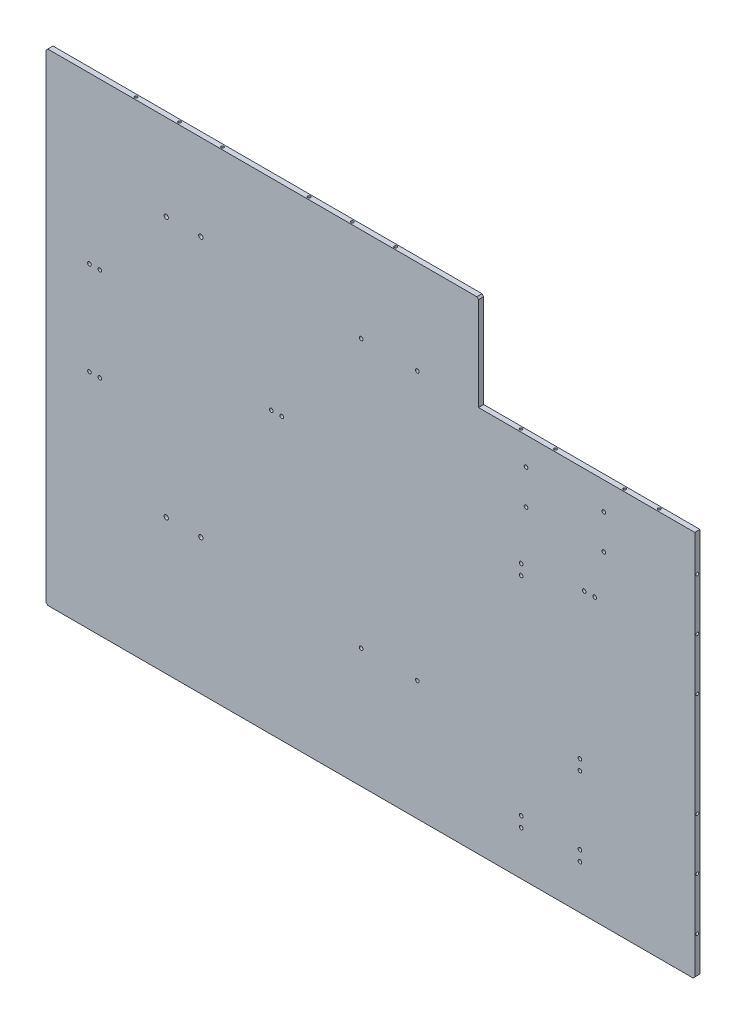
from build123d import *

# Parameters (mm, degrees)
SKETCH_1_W             = 610
SKETCH_1_H             = 420
EXTRUDE_1_DEPTH        = 6
HOLE_WIZARD_M6_1_D     = 5
HOLE_WIZARD_M6_1_DEPTH = 15
HOLE_WIZARD_M6_1_TIP   = 1.502151548
HOLE_WIZARD_M5_1_D     = 4.2
HOLE_WIZARD_M5_1_DEPTH = 12.4
HOLE_WIZARD_M5_1_TIP   = 1.2618073
HOLE_WIZARD_M5_2_D     = 4.2
HOLE_WIZARD_M5_2_DEPTH = 12.4
HOLE_WIZARD_M5_2_TIP   = 1.2618073
HOLE_WIZARD_M6_2_D     = 5
HOLE_WIZARD_M6_2_DEPTH = 15
HOLE_WIZARD_M6_2_TIP   = 1.502151548
HOLE_WIZARD_M5_3_D     = 4.2
HOLE_WIZARD_M5_3_DEPTH = 12.4
HOLE_WIZARD_M5_3_TIP   = 1.2618073
HOLE_WIZARD_M5_4_D     = 4.2
HOLE_WIZARD_M5_4_DEPTH = 12.4
HOLE_WIZARD_M5_4_TIP   = 1.2618073
HOLE_WIZARD_M5_5_D     = 4.2
HOLE_WIZARD_M5_5_DEPTH = 12.4
HOLE_WIZARD_M5_5_TIP   = 1.2618073
HOLE_WIZARD_M5_6_D     = 4.2
HOLE_WIZARD_M5_6_DEPTH = 12.4
HOLE_WIZARD_M5_6_TIP   = 1.2618073
HOLE_WIZARD_M5_7_D     = 4.2
HOLE_WIZARD_M5_7_DEPTH = 12.4
HOLE_WIZARD_M5_7_TIP   = 1.2618073
SKETCH_22_W            = 610
SKETCH_22_H            = 6
EXTRUDE_2_DEPTH        = 47.17
SKETCH_23_W            = 610
SKETCH_23_H            = 6
EXTRUDE_3_DEPTH        = 90
SKETCH_24_W            = 6
SKETCH_24_H            = 557.17
EXTRUDE_4_DEPTH        = 39.94
SKETCH_25_W            = 6
SKETCH_25_H            = 557.17
EXTRUDE_5_DEPTH        = 100.06
SKETCH_26_W            = 250
SKETCH_26_H            = 110
CUT_EXTRUDE_1_DEPTH    = 100.06
CHAMFER_2_SIZE         = 2
CHAMFER_3_SIZE         = 2
CHAMFER_4_SIZE         = 2
CHAMFER_5_SIZE         = 2
HOLE_WIZARD_M4_1_D     = 3.3
HOLE_WIZARD_M4_1_DEPTH = 10.1
HOLE_WIZARD_M4_1_TIP   = 0.991420021
HOLE_WIZARD_M4_2_D     = 3.3
HOLE_WIZARD_M4_2_DEPTH = 10.1
HOLE_WIZARD_M4_2_TIP   = 0.991420021
HOLE_WIZARD_M4_3_D     = 3.3
HOLE_WIZARD_M4_3_DEPTH = 10.1
HOLE_WIZARD_M4_3_TIP   = 0.991420021
HOLE_WIZARD_M4_4_D     = 3.3
HOLE_WIZARD_M4_4_DEPTH = 10.1
HOLE_WIZARD_M4_4_TIP   = 0.991420021
HOLE_WIZARD_M4_5_D     = 3.3
HOLE_WIZARD_M4_5_DEPTH = 10.1
HOLE_WIZARD_M4_5_TIP   = 0.991420021


with BuildPart() as part:
    # 草图1 → 凸台-拉伸1 (new body)
    with BuildSketch(Plane.XY):
        with Locations((305, 210)):
            Rectangle(SKETCH_1_W, SKETCH_1_H)
    extrude(amount=EXTRUDE_1_DEPTH)

    # M6 螺纹孔1
    with Locations(Plane.XY.offset(6)):
        with Locations((99, 410.6), (139, 410.6)):
            Hole(HOLE_WIZARD_M6_1_D / 2, depth=HOLE_WIZARD_M6_1_DEPTH)
            with Locations((0, 0, -(HOLE_WIZARD_M6_1_DEPTH + HOLE_WIZARD_M6_1_TIP / 2))):  # 118° drill point
                Cone(0, HOLE_WIZARD_M6_1_D / 2, HOLE_WIZARD_M6_1_TIP, mode=Mode.SUBTRACT)

    # M5 螺纹孔1
    with Locations(Plane.XY.offset(6)):
        with Locations((10.231581543, 318.9), (22.231581543, 318.9)):
            Hole(HOLE_WIZARD_M5_1_D / 2, depth=HOLE_WIZARD_M5_1_DEPTH)
            with Locations((0, 0, -(HOLE_WIZARD_M5_1_DEPTH + HOLE_WIZARD_M5_1_TIP / 2))):  # 118° drill point
                Cone(0, HOLE_WIZARD_M5_1_D / 2, HOLE_WIZARD_M5_1_TIP, mode=Mode.SUBTRACT)

    # M5 螺纹孔2
    with Locations(Plane.XY.offset(6)):
        with Locations((10.231581543, 210.9), (22.231581543, 210.9)):
            Hole(HOLE_WIZARD_M5_2_D / 2, depth=HOLE_WIZARD_M5_2_DEPTH)
            with Locations((0, 0, -(HOLE_WIZARD_M5_2_DEPTH + HOLE_WIZARD_M5_2_TIP / 2))):  # 118° drill point
                Cone(0, HOLE_WIZARD_M5_2_D / 2, HOLE_WIZARD_M5_2_TIP, mode=Mode.SUBTRACT)

    # M6 螺纹孔2
    with Locations(Plane.XY.offset(6)):
        with Locations((99, 109.6), (139, 109.6)):
            Hole(HOLE_WIZARD_M6_2_D / 2, depth=HOLE_WIZARD_M6_2_DEPTH)
            with Locations((0, 0, -(HOLE_WIZARD_M6_2_DEPTH + HOLE_WIZARD_M6_2_TIP / 2))):  # 118° drill point
                Cone(0, HOLE_WIZARD_M6_2_D / 2, HOLE_WIZARD_M6_2_TIP, mode=Mode.SUBTRACT)

    # M5 螺纹孔3
    with Locations(Plane.XY.offset(6)):
        with Locations((515, 367.9), (515, 327.9), (605, 327.9), (605, 367.9)):
            Hole(HOLE_WIZARD_M5_3_D / 2, depth=HOLE_WIZARD_M5_3_DEPTH)
            with Locations((0, 0, -(HOLE_WIZARD_M5_3_DEPTH + HOLE_WIZARD_M5_3_TIP / 2))):  # 118° drill point
                Cone(0, HOLE_WIZARD_M5_3_D / 2, HOLE_WIZARD_M5_3_TIP, mode=Mode.SUBTRACT)

    # M5 螺纹孔4
    with Locations(Plane.XY.offset(6)):
        with Locations((582.231581543, 277.4), (594.231581543, 277.4), (509.3, 268.5), (509.3, 256.5), (509.3, 16), (509.3, 4), (577.3, 16), (577.3, 4), (577.3, 95), (577.3, 107)):
            Hole(HOLE_WIZARD_M5_4_D / 2, depth=HOLE_WIZARD_M5_4_DEPTH)
            with Locations((0, 0, -(HOLE_WIZARD_M5_4_DEPTH + HOLE_WIZARD_M5_4_TIP / 2))):  # 118° drill point
                Cone(0, HOLE_WIZARD_M5_4_D / 2, HOLE_WIZARD_M5_4_TIP, mode=Mode.SUBTRACT)

    # M5 螺纹孔5
    with Locations(Plane.XY.offset(6)):
        with Locations((220.520192359, 277.4), (232.520192359, 277.4)):
            Hole(HOLE_WIZARD_M5_5_D / 2, depth=HOLE_WIZARD_M5_5_DEPTH)
            with Locations((0, 0, -(HOLE_WIZARD_M5_5_DEPTH + HOLE_WIZARD_M5_5_TIP / 2))):  # 118° drill point
                Cone(0, HOLE_WIZARD_M5_5_D / 2, HOLE_WIZARD_M5_5_TIP, mode=Mode.SUBTRACT)

    # M5 螺纹孔6
    with Locations(Plane.XY.offset(6)):
        with Locations((324.3072517, 91.214749506), (389.3072517, 91.214749506)):
            Hole(HOLE_WIZARD_M5_6_D / 2, depth=HOLE_WIZARD_M5_6_DEPTH)
            with Locations((0, 0, -(HOLE_WIZARD_M5_6_DEPTH + HOLE_WIZARD_M5_6_TIP / 2))):  # 118° drill point
                Cone(0, HOLE_WIZARD_M5_6_D / 2, HOLE_WIZARD_M5_6_TIP, mode=Mode.SUBTRACT)

    # M5 螺纹孔7
    with Locations(Plane.XY.offset(6)):
        with Locations((324.3072517, 401.214749506), (389.3072517, 401.214749506)):
            Hole(HOLE_WIZARD_M5_7_D / 2, depth=HOLE_WIZARD_M5_7_DEPTH)
            with Locations((0, 0, -(HOLE_WIZARD_M5_7_DEPTH + HOLE_WIZARD_M5_7_TIP / 2))):  # 118° drill point
                Cone(0, HOLE_WIZARD_M5_7_D / 2, HOLE_WIZARD_M5_7_TIP, mode=Mode.SUBTRACT)

    # 草图22 → 凸台-拉伸2 (add)
    with BuildSketch(Plane.XZ):
        with Locations((305, 3)):
            Rectangle(SKETCH_22_W, SKETCH_22_H)
    extrude(amount=EXTRUDE_2_DEPTH)

    # 草图23 → 凸台-拉伸3 (add)
    with BuildSketch(Plane(origin=(0, 420, 0), x_dir=(1, 0, 0), z_dir=(0, 1, 0))):
        with Locations((305, -3)):
            Rectangle(SKETCH_23_W, SKETCH_23_H)
    extrude(amount=EXTRUDE_3_DEPTH)

    # 草图24 → 凸台-拉伸4 (add)
    with BuildSketch(Plane.ZY):
        with Locations((3, 231.415)):
            Rectangle(SKETCH_24_W, SKETCH_24_H)
    extrude(amount=EXTRUDE_4_DEPTH)

    # 草图25 → 凸台-拉伸5 (add)
    with BuildSketch(Plane(origin=(610, 0, 0), x_dir=(0, 0, -1), z_dir=(1, 0, 0))):
        with Locations((-3, 231.415)):
            Rectangle(SKETCH_25_W, SKETCH_25_H)
    extrude(amount=EXTRUDE_5_DEPTH)

    # 草图26 → 切除-拉伸1 (cut)
    with BuildSketch(Plane.XY.offset(6)):
        with Locations((585.06, 455)):
            Rectangle(SKETCH_26_W, SKETCH_26_H)
    extrude(amount=-CUT_EXTRUDE_1_DEPTH, mode=Mode.SUBTRACT)

    # 倒角2
    chamfer_2_edges = [part.edges().sort_by_distance(p)[0] for p in [
        (710.06, -47.17, 3),
    ]]
    chamfer(chamfer_2_edges, length=CHAMFER_2_SIZE)

    # 倒角3
    chamfer_3_edges = [part.edges().sort_by_distance(p)[0] for p in [
        (-39.94, -47.17, 3),
    ]]
    chamfer(chamfer_3_edges, length=CHAMFER_3_SIZE)

    # 倒角4
    chamfer_4_edges = [part.edges().sort_by_distance(p)[0] for p in [
        (-39.94, 510, 3),
    ]]
    chamfer(chamfer_4_edges, length=CHAMFER_4_SIZE)

    # 倒角5
    chamfer_5_edges = [part.edges().sort_by_distance(p)[0] for p in [
        (460.06, 510, 3),
    ]]
    chamfer(chamfer_5_edges, length=CHAMFER_5_SIZE)

    # M4 螺纹孔1
    with Locations(Plane(origin=(0, -47.17, 0), x_dir=(-1, 0, 0), z_dir=(0, -1, 0))):
        with Locations((-35.061581543, -3), (-135.061581543, -3), (-235.061581543, -3), (-435.061581543, -3), (-535.061581543, -3), (-635.061581543, -3)):
            Hole(HOLE_WIZARD_M4_1_D / 2, depth=HOLE_WIZARD_M4_1_DEPTH)
            with Locations((0, 0, -(HOLE_WIZARD_M4_1_DEPTH + HOLE_WIZARD_M4_1_TIP / 2))):  # 118° drill point
                Cone(0, HOLE_WIZARD_M4_1_D / 2, HOLE_WIZARD_M4_1_TIP, mode=Mode.SUBTRACT)

    # M4 螺纹孔2
    with Locations(Plane.ZY.offset(39.94)):
        with Locations((3, 471.4166), (3, 391.4166), (3, 311.4166), (3, 151.4166), (3, 71.4166), (3, -8.5834)):
            Hole(HOLE_WIZARD_M4_2_D / 2, depth=HOLE_WIZARD_M4_2_DEPTH)
            with Locations((0, 0, -(HOLE_WIZARD_M4_2_DEPTH + HOLE_WIZARD_M4_2_TIP / 2))):  # 118° drill point
                Cone(0, HOLE_WIZARD_M4_2_D / 2, HOLE_WIZARD_M4_2_TIP, mode=Mode.SUBTRACT)

    # M4 螺纹孔3
    with Locations(Plane(origin=(0, 510, 0), x_dir=(1, 0, 0), z_dir=(0, 1, 0))):
        with Locations((361.179881543, -3), (311.179881543, -3), (261.179881543, -3), (161.179881543, -3), (111.179881543, -3), (61.179881543, -3)):
            Hole(HOLE_WIZARD_M4_3_D / 2, depth=HOLE_WIZARD_M4_3_DEPTH)
            with Locations((0, 0, -(HOLE_WIZARD_M4_3_DEPTH + HOLE_WIZARD_M4_3_TIP / 2))):  # 118° drill point
                Cone(0, HOLE_WIZARD_M4_3_D / 2, HOLE_WIZARD_M4_3_TIP, mode=Mode.SUBTRACT)

    # M4 螺纹孔4
    with Locations(Plane(origin=(710.06, 0, 0), x_dir=(0, 0, -1), z_dir=(1, 0, 0))):
        with Locations((-3, -3.2184), (-3, 56.7816), (-3, 116.7816), (-3, 236.7816), (-3, 296.7816), (-3, 356.7816)):
            Hole(HOLE_WIZARD_M4_4_D / 2, depth=HOLE_WIZARD_M4_4_DEPTH)
            with Locations((0, 0, -(HOLE_WIZARD_M4_4_DEPTH + HOLE_WIZARD_M4_4_TIP / 2))):  # 118° drill point
                Cone(0, HOLE_WIZARD_M4_4_D / 2, HOLE_WIZARD_M4_4_TIP, mode=Mode.SUBTRACT)

    # M4 螺纹孔5
    with Locations(Plane(origin=(0, 400, 0), x_dir=(1, 0, 0), z_dir=(0, 1, 0))):
        with Locations((666.061581543, -3), (626.061581543, -3), (546.061581543, -3), (506.061581543, -3)):
            Hole(HOLE_WIZARD_M4_5_D / 2, depth=HOLE_WIZARD_M4_5_DEPTH)
            with Locations((0, 0, -(HOLE_WIZARD_M4_5_DEPTH + HOLE_WIZARD_M4_5_TIP / 2))):  # 118° drill point
                Cone(0, HOLE_WIZARD_M4_5_D / 2, HOLE_WIZARD_M4_5_TIP, mode=Mode.SUBTRACT)


solid = part.part
